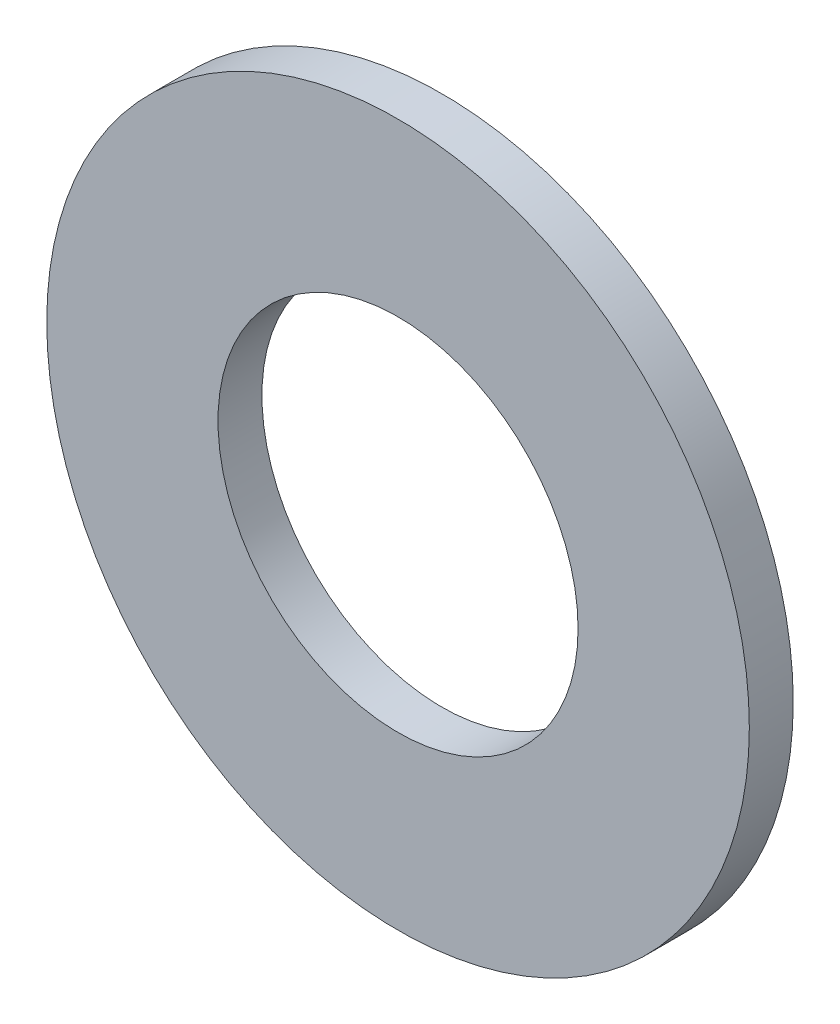
from build123d import *

# Parameters (mm, degrees)
SKETCH1_W                  = 8
SKETCH1_H                  = 1
F_8_2_8_2_DIAMETER_HOLE1_D = 8.2


with BuildPart() as part:
    # Sketch1 → Revolve1 (revolve)
    with BuildSketch(Plane(origin=(0, 0, 0), x_dir=(1, 0, 0), z_dir=(0, 1, 0))):
        with Locations((-4, 0)):
            Rectangle(SKETCH1_W, SKETCH1_H)
    revolve(axis=Axis((0, 0, 20.364809028), (0, 0, -1)))

    # Ø8.2 (8.2) Diameter Hole1 (through all)
    with Locations(Plane.XY.offset(0.5)):
        with Locations((0, 0)):
            Hole(F_8_2_8_2_DIAMETER_HOLE1_D / 2)


solid = part.part
